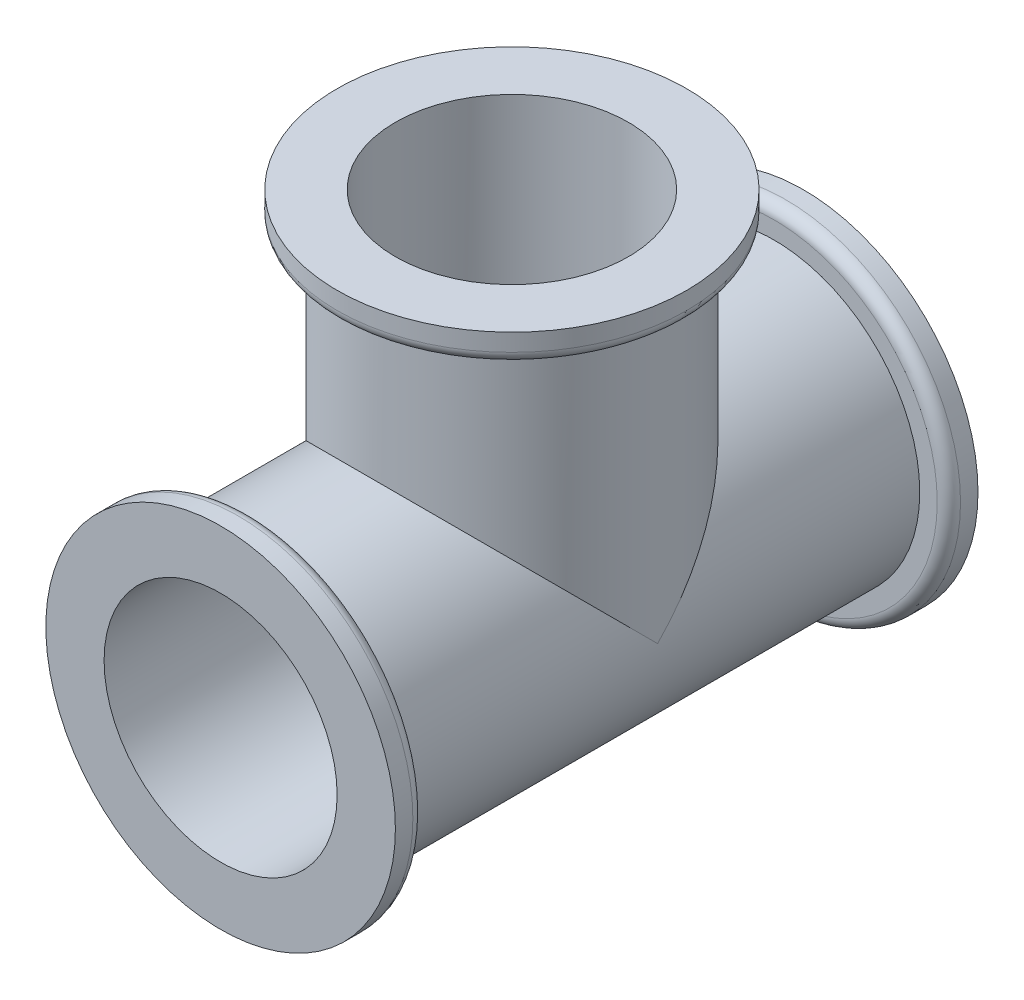
from build123d import *

# Parameters (mm, degrees)
CROQUIS1_R            = 15
CROQUIS1_R_2          = 10
EXTRUIR_L_MINA1_DEPTH = 2.5
CROQUIS2_R            = 12.5
CROQUIS2_R_2          = 10
EXTRUIR_L_MINA2_DEPTH = 45
REDONDEO3_R           = 1
CROQUIS5_R            = 12.5
CROQUIS5_R_2          = 10
EXTRUIR_L_MINA3_DEPTH = 25
CROQUIS6_R            = 15
CROQUIS6_R_2          = 10
EXTRUIR_L_MINA4_DEPTH = 2.5
REDONDEO4_R           = 1
CROQUIS7_R            = 10
CORTAR_EXTRUIR1_DEPTH = 51
CROQUIS8_R            = 10
CORTAR_EXTRUIR2_DEPTH = 28


with BuildPart() as part:
    # Croquis1 → Extruir-Lámina1 (new body)
    with BuildSketch(Plane.XY):
        Circle(CROQUIS1_R)
        Circle(CROQUIS1_R_2, mode=Mode.SUBTRACT)
    extruir_l_mina1 = extrude(amount=EXTRUIR_L_MINA1_DEPTH)

    # Croquis2 → Extruir-Lámina2 (add)
    with BuildSketch(Plane(origin=(0, 0, 0), x_dir=(-1, 0, 0), z_dir=(0, 0, -1))):
        Circle(CROQUIS2_R)
        Circle(CROQUIS2_R_2, mode=Mode.SUBTRACT)
    extrude(amount=EXTRUIR_L_MINA2_DEPTH)

    # Simetría1: Extruir-Lámina1 across plane
    add(extruir_l_mina1.mirror(Plane.XY.offset(-22.5)))

    # Redondeo3
    redondeo3_edges = [part.edges().sort_by_distance(p)[0] for p in [
        (-15, 0, -45),
        (-15, 0, 0),
    ]]
    fillet(redondeo3_edges, radius=REDONDEO3_R)

    # Croquis5 → Extruir-Lámina3 (add)
    with BuildSketch(Plane(origin=(0, 0, 0), x_dir=(1, 0, 0), z_dir=(0, 1, 0))):
        with Locations((0, 22.5)):
            Circle(CROQUIS5_R)
        with Locations((0, 22.5)):
            Circle(CROQUIS5_R_2, mode=Mode.SUBTRACT)
    extrude(amount=EXTRUIR_L_MINA3_DEPTH)

    # Croquis6 → Extruir-Lámina4 (add)
    with BuildSketch(Plane(origin=(0, 25, 0), x_dir=(1, 0, 0), z_dir=(0, 1, 0))):
        with Locations((0, 22.5)):
            Circle(CROQUIS6_R)
        with Locations((0, 22.5)):
            Circle(CROQUIS6_R_2, mode=Mode.SUBTRACT)
    extrude(amount=EXTRUIR_L_MINA4_DEPTH)

    # Redondeo4
    redondeo4_edges = [part.edges().sort_by_distance(p)[0] for p in [
        (-15, 25, -22.5),
    ]]
    fillet(redondeo4_edges, radius=REDONDEO4_R)

    # Croquis7 → Cortar-Extruir1 (cut, through all)
    with BuildSketch(Plane(origin=(0, 0, -47.5), x_dir=(-1, 0, 0), z_dir=(0, 0, -1))):
        Circle(CROQUIS7_R)
    extrude(amount=-CORTAR_EXTRUIR1_DEPTH, mode=Mode.SUBTRACT)

    # Croquis8 → Cortar-Extruir2 (cut)
    with BuildSketch(Plane(origin=(0, 27.5, 0), x_dir=(1, 0, 0), z_dir=(0, 1, 0))):
        with Locations((0, 22.5)):
            Circle(CROQUIS8_R)
    extrude(amount=-CORTAR_EXTRUIR2_DEPTH, mode=Mode.SUBTRACT)


solid = part.part
